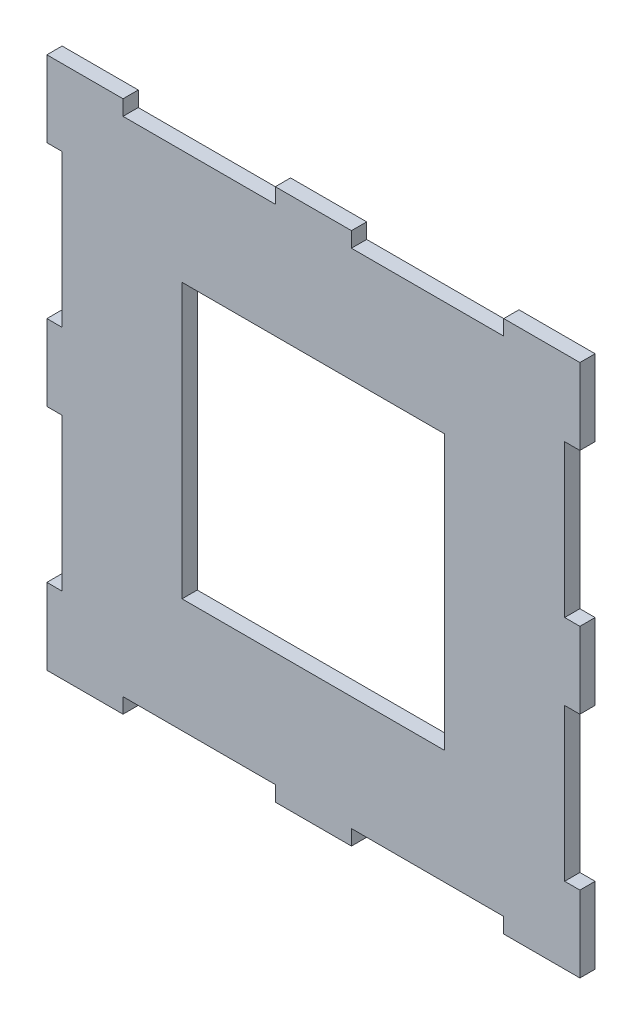
from build123d import *

# Parameters (mm, degrees)
SKETCH1_W           = 70
SKETCH1_H           = 70
SKETCH1_W_2         = 34.5
SKETCH1_H_2         = 36
BOSS_EXTRUDE1_DEPTH = 2
SKETCH2_W           = 2
SKETCH2_H           = 20
SKETCH2_W_2         = 20
SKETCH2_H_2         = 2
CUT_EXTRUDE1_DEPTH  = 2


with BuildPart() as part:
    # Sketch1 → Boss-Extrude1 (new body)
    with BuildSketch(Plane.XY):
        Rectangle(SKETCH1_W, SKETCH1_H)
        Rectangle(SKETCH1_W_2, SKETCH1_H_2, mode=Mode.SUBTRACT)
    extrude(amount=-BOSS_EXTRUDE1_DEPTH)

    # Sketch2 → Cut-Extrude1 (cut)
    with BuildSketch(Plane.XY):
        with Locations((-34, 15)):
            Rectangle(SKETCH2_W, SKETCH2_H)
        with Locations((-34, -15)):
            Rectangle(SKETCH2_W, SKETCH2_H)
        with Locations((-15, -34)):
            Rectangle(SKETCH2_W_2, SKETCH2_H_2)
        with Locations((15, -34)):
            Rectangle(SKETCH2_W_2, SKETCH2_H_2)
        with Locations((34, -15)):
            Rectangle(SKETCH2_W, SKETCH2_H)
        with Locations((34, 15)):
            Rectangle(SKETCH2_W, SKETCH2_H)
        with Locations((15, 34)):
            Rectangle(SKETCH2_W_2, SKETCH2_H_2)
        with Locations((-15, 34)):
            Rectangle(SKETCH2_W_2, SKETCH2_H_2)
    extrude(amount=-CUT_EXTRUDE1_DEPTH, mode=Mode.SUBTRACT)


solid = part.part
